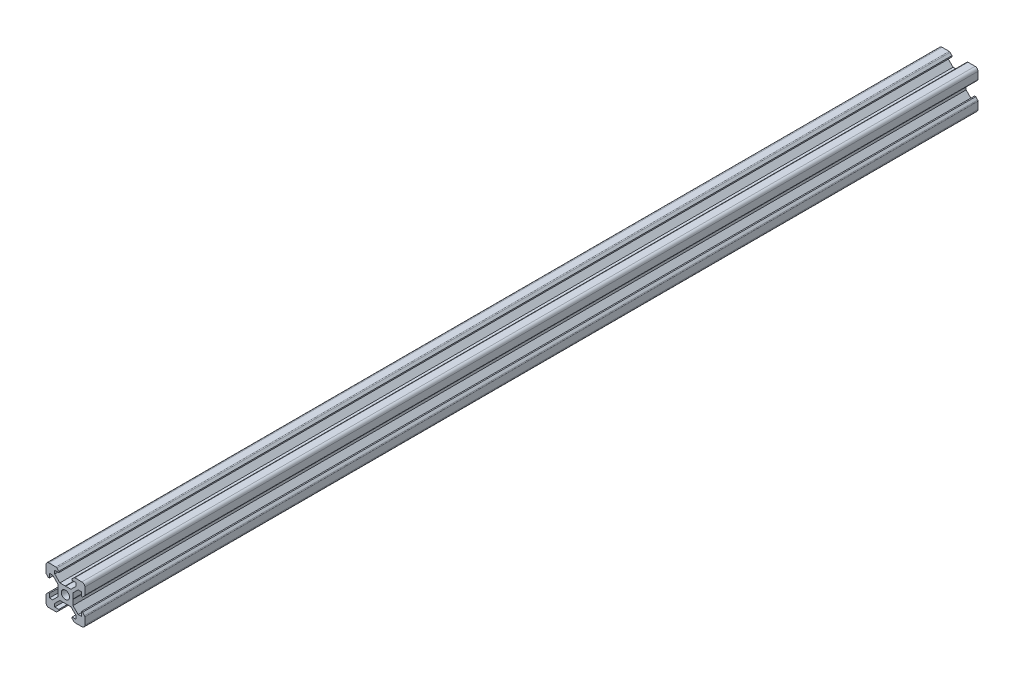
from build123d import *

# Parameters (mm, degrees)
SKETCH1_R           = 2.1
BOSS_EXTRUDE1_DEPTH = 460


with BuildPart() as part:
    # Sketch1 → Boss-Extrude1 (new body)
    with BuildSketch(Plane.XY):
        with BuildLine():
            Line((-8.5, 10), (-4.862792737, 10))
            ThreePointArc((-4.862792737, 10), (-4.598292737, 9.947387679), (-4.374060464, 9.797560464))
            Line((-4.374060464, 9.797560464), (-3.3865, 8.81))
            Line((-3.3865, 8.81), (-3.3865, 8.2))
            Line((-3.3865, 8.2), (-5.5, 8.2))
            Line((-5.5, 8.2), (-5.5, 6.561))
            Line((-5.5, 6.561), (-2.8395, 3.9005))
            Line((-2.8395, 3.9005), (-0.1, 3.9005))
            Line((-0.1, 3.9005), (0, 3.8005))
            Line((0, 3.8005), (0.1, 3.9005))
            Line((0.1, 3.9005), (2.8395, 3.9005))
            Line((2.8395, 3.9005), (5.5, 6.561))
            Line((5.5, 6.561), (5.5, 8.2))
            Line((5.5, 8.2), (3.3865, 8.2))
            Line((3.3865, 8.2), (3.3865, 8.81))
            Line((3.3865, 8.81), (4.374060464, 9.797560464))
            ThreePointArc((4.374060464, 9.797560464), (4.598292737, 9.947387679), (4.862792737, 10))
            Line((4.862792737, 10), (8.5, 10))
            ThreePointArc((8.5, 10), (9.560660172, 9.560660172), (10, 8.5))
            Line((10, 8.5), (10, 4.862792737))
            ThreePointArc((10, 4.862792737), (9.947387679, 4.598292737), (9.797560464, 4.374060464))
            Line((9.797560464, 4.374060464), (8.81, 3.3865))
            Line((8.81, 3.3865), (8.2, 3.3865))
            Line((8.2, 3.3865), (8.2, 5.5))
            Line((8.2, 5.5), (6.561, 5.5))
            Line((6.561, 5.5), (3.9005, 2.8395))
            Line((3.9005, 2.8395), (3.9005, 0.1))
            Line((3.9005, 0.1), (3.8005, 0))
            Line((3.8005, 0), (3.9005, -0.1))
            Line((3.9005, -0.1), (3.9005, -2.8395))
            Line((3.9005, -2.8395), (6.561, -5.5))
            Line((6.561, -5.5), (8.2, -5.5))
            Line((8.2, -5.5), (8.2, -3.3865))
            Line((8.2, -3.3865), (8.81, -3.3865))
            Line((8.81, -3.3865), (9.797560464, -4.374060464))
            ThreePointArc((9.797560464, -4.374060464), (9.947387679, -4.598292737), (10, -4.862792737))
            Line((10, -4.862792737), (10, -8.5))
            ThreePointArc((10, -8.5), (9.560660172, -9.560660172), (8.5, -10))
            Line((8.5, -10), (4.862792737, -10))
            ThreePointArc((4.862792737, -10), (4.598292737, -9.947387679), (4.374060464, -9.797560464))
            Line((4.374060464, -9.797560464), (3.3865, -8.81))
            Line((3.3865, -8.81), (3.3865, -8.2))
            Line((3.3865, -8.2), (5.5, -8.2))
            Line((5.5, -8.2), (5.5, -6.561))
            Line((5.5, -6.561), (2.8395, -3.9005))
            Line((2.8395, -3.9005), (0.1, -3.9005))
            Line((0.1, -3.9005), (0, -3.8005))
            Line((0, -3.8005), (-0.1, -3.9005))
            Line((-0.1, -3.9005), (-2.8395, -3.9005))
            Line((-2.8395, -3.9005), (-5.5, -6.561))
            Line((-5.5, -6.561), (-5.5, -8.2))
            Line((-5.5, -8.2), (-3.3865, -8.2))
            Line((-3.3865, -8.2), (-3.3865, -8.81))
            Line((-3.3865, -8.81), (-4.374060464, -9.797560464))
            ThreePointArc((-4.374060464, -9.797560464), (-4.598292737, -9.947387679), (-4.862792737, -10))
            Line((-4.862792737, -10), (-8.5, -10))
            ThreePointArc((-8.5, -10), (-9.560660172, -9.560660172), (-10, -8.5))
            Line((-10, -8.5), (-10, -4.862792737))
            ThreePointArc((-10, -4.862792737), (-9.947387679, -4.598292737), (-9.797560464, -4.374060464))
            Line((-9.797560464, -4.374060464), (-8.81, -3.3865))
            Line((-8.81, -3.3865), (-8.2, -3.3865))
            Line((-8.2, -3.3865), (-8.2, -5.5))
            Line((-8.2, -5.5), (-6.561, -5.5))
            Line((-6.561, -5.5), (-3.9005, -2.8395))
            Line((-3.9005, -2.8395), (-3.9005, -0.1))
            Line((-3.9005, -0.1), (-3.8005, 0))
            Line((-3.8005, 0), (-3.9005, 0.1))
            Line((-3.9005, 0.1), (-3.9005, 2.8395))
            Line((-3.9005, 2.8395), (-6.561, 5.5))
            Line((-6.561, 5.5), (-8.2, 5.5))
            Line((-8.2, 5.5), (-8.2, 3.3865))
            Line((-8.2, 3.3865), (-8.81, 3.3865))
            Line((-8.81, 3.3865), (-9.797560464, 4.374060464))
            ThreePointArc((-9.797560464, 4.374060464), (-9.947387679, 4.598292737), (-10, 4.862792737))
            Line((-10, 4.862792737), (-10, 8.5))
            ThreePointArc((-10, 8.5), (-9.560660172, 9.560660172), (-8.5, 10))
        make_face()
        Circle(SKETCH1_R, mode=Mode.SUBTRACT)
    extrude(amount=BOSS_EXTRUDE1_DEPTH)


solid = part.part
